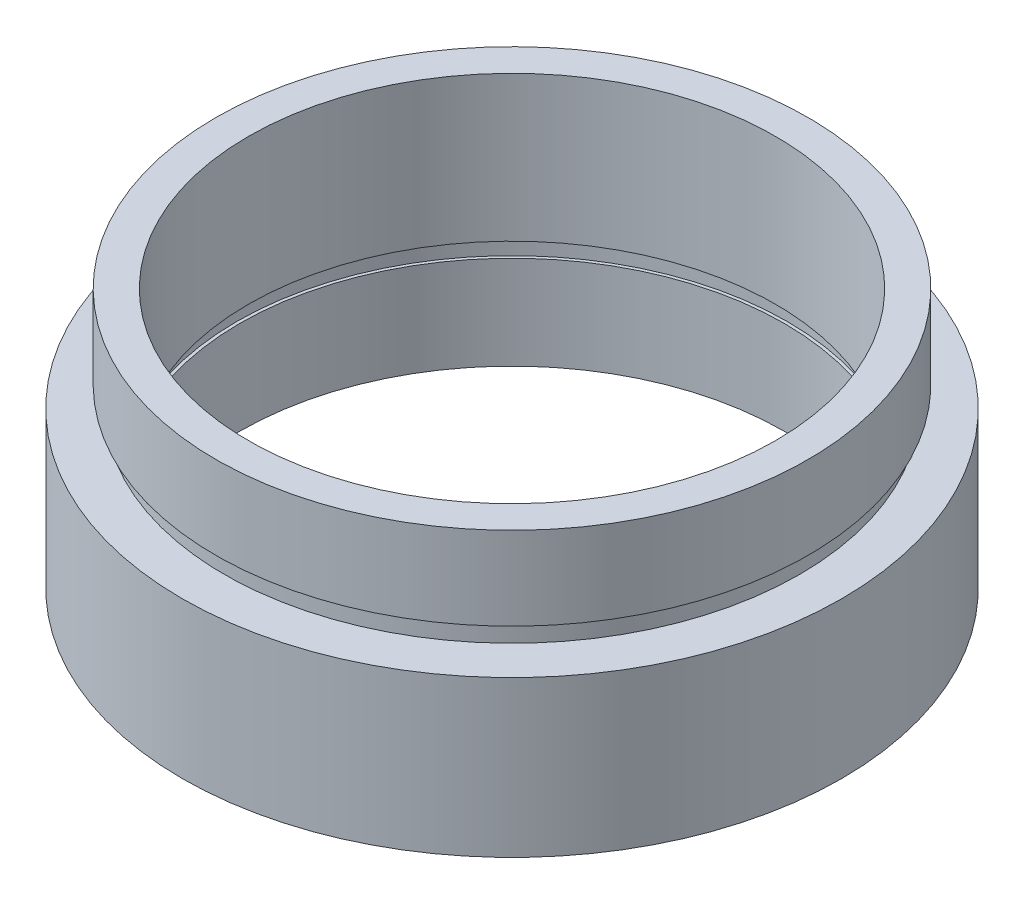
from build123d import *


with BuildPart() as part:
    # 草图1 → 旋转1 (revolve)
    with BuildSketch(Plane.XY, mode=Mode.PRIVATE) as revolve_1_sk:
        Polygon((13.1, 0), (13.1, 4.5), (13.25, 4.5), (13.25, 5.5), (12.69, 5.5), (12.69, 12.5), (14.26, 12.5), (14.26, 8.5), (13.85, 8.5), (13.85, 7.5), (15.875, 7.5), (15.875, 0), align=None)
    revolve(revolve_1_sk.sketch.rotate(Axis((0, 16.886018237, 0), (0, -1, 0)), 180), axis=Axis((0, 16.886018237, 0), (0, -1, 0)))  # turned: the seam where the file's is


solid = part.part
